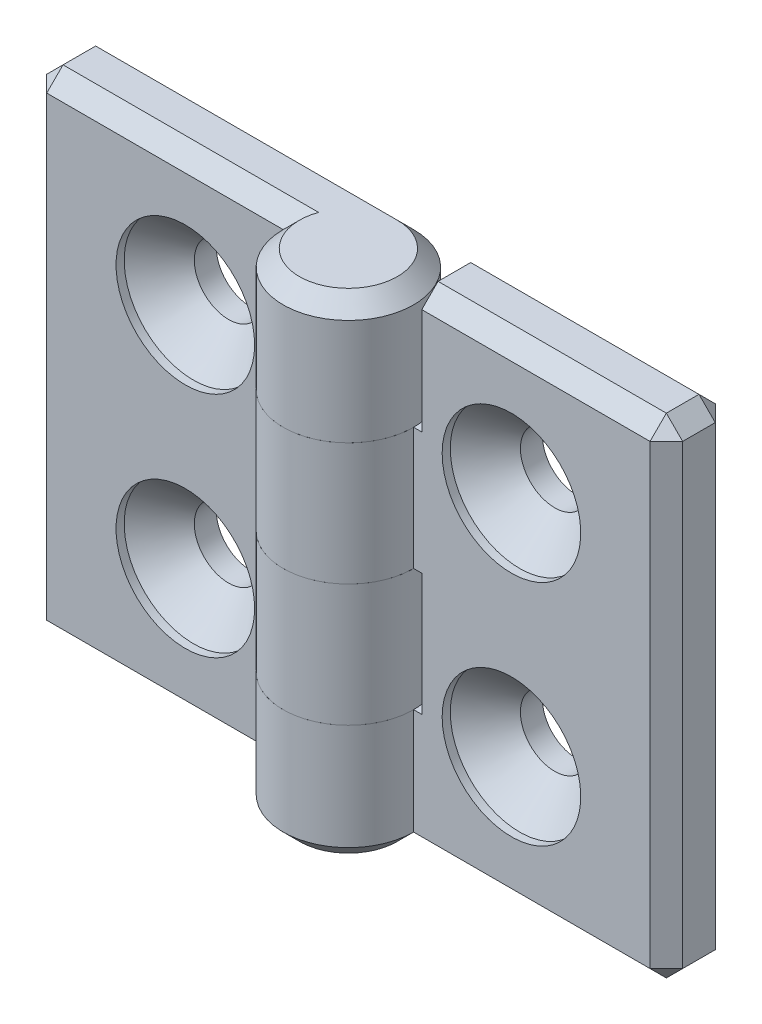
from build123d import *

# Parameters (mm, degrees)
EXTRUDE_1_DEPTH            = 15
SKETCH_3_W                 = 8.5
SKETCH_3_H                 = 7.5
CUT_EXTRUDE_1_DEPTH        = 5
CUT_EXTRUDE_1_DEPTH_BACK   = 5
HOLE_WIZARD_M41_AT_2_COUNT = 2
HOLE_WIZARD_M41_AT_2_PITCH = 14
CHAMFER_1_SIZE             = 1
PATTERN_CIRCULAR_1_COUNT   = 2


with BuildPart() as part:
    # Эскиз1 → Бобышка-Вытянуть1 (new body, symmetric)
    with BuildSketch(Plane(origin=(0, 0, 0), x_dir=(1, 0, 0), z_dir=(0, 1, 0))):
        with BuildLine():
            Line((0, 4), (-19.5, 4))
            Line((-19.5, 4), (-19.5, 0))
            Line((-19.5, 0), (-4, 0))
            ThreePointArc((-4, 0), (2.828427125, -2.828427125), (0, 4))
        make_face()
    extrude(amount=EXTRUDE_1_DEPTH, both=True)

    # Эскиз3 → Вырез-Вытянуть1 (cut, two sides)
    with BuildSketch(Plane.XY) as cut_extrude_1_sk:
        with Locations((-0.25, 3.75)):
            Rectangle(SKETCH_3_W, SKETCH_3_H)
        with Locations((-0.25, -11.25)):
            Rectangle(SKETCH_3_W, SKETCH_3_H)
    extrude(amount=CUT_EXTRUDE_1_DEPTH, mode=Mode.SUBTRACT)
    extrude(cut_extrude_1_sk.sketch, amount=-CUT_EXTRUDE_1_DEPTH_BACK, mode=Mode.SUBTRACT)

    # Эскиз6 → Зенковка для винта с полупотайной головкой M41 (revolve, cut)
    with BuildSketch(Plane(origin=(-10, 7, 0), x_dir=(0, -1, 0), z_dir=(1, 0, 0))):
        Polygon((0, 0), (0, 4), (2.1, 4), (2.1, 2.65), (4.25, 0.5), (4.25, 0), align=None)
    hole_wizard_m41 = revolve(axis=Axis((-10, 7, 6.35), (0, 0, -1)), mode=Mode.SUBTRACT)

    # Зенковка для винта с полупотайной головкой M41 at 2: Зенковка для винта с полупотайной головкой M41 ×2
    with Locations(*[(0, -i * HOLE_WIZARD_M41_AT_2_PITCH, 0) for i in range(1, HOLE_WIZARD_M41_AT_2_COUNT)]):
        add(hole_wizard_m41, mode=Mode.SUBTRACT)

    # Фаска1
    chamfer_1_edges = [part.edges().sort_by_distance(p)[0] for p in [
        (-19.5, 15, -2),
        (-12, -15, -4),
        (-11.75, 15, 0),
        (2.828427125, 15, 2.828427125),
        (-12, -15, 0),
        (-19.5, -15, -2),
        (-19.5, 0, 0),
        (-19.5, 0, -4),
        (-9.75, 15, -4),
    ]]
    chamfer(chamfer_1_edges, length=CHAMFER_1_SIZE)


with BuildPart() as pattern_circular_1_1:
    # Круговой массив1: pattern copy
    add(part.part.rotate(Axis((0, 0, 0), (0, 0, 1)), 1 * 360 / PATTERN_CIRCULAR_1_COUNT))


solid = Compound([part.part, pattern_circular_1_1.part])
